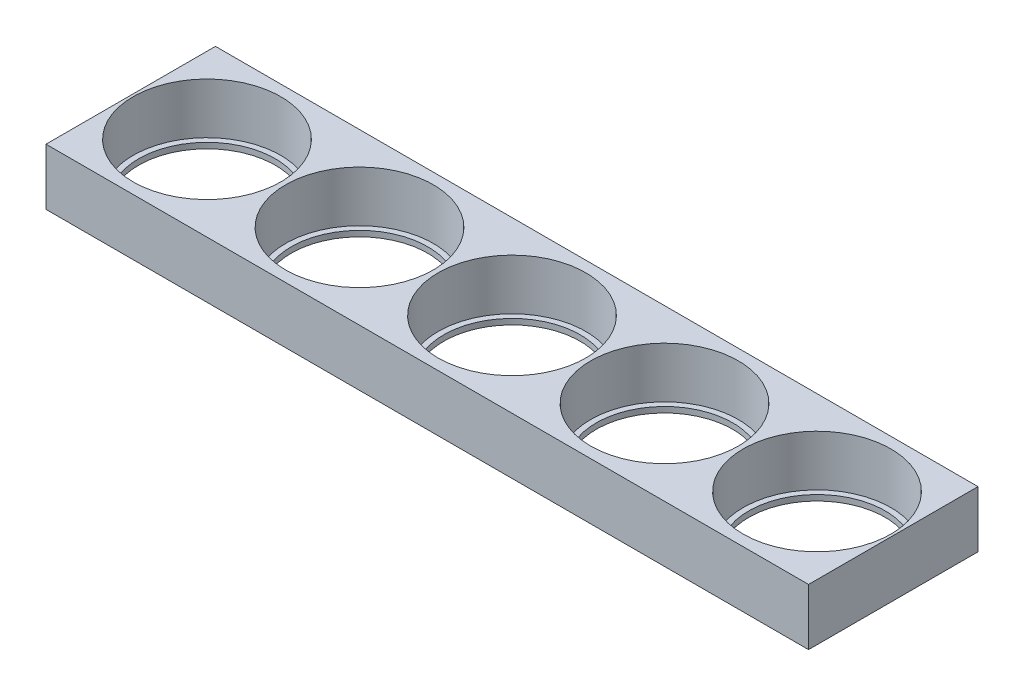
from build123d import *

# Parameters (mm, degrees)
ESQUISSE1_W                    = 27
ESQUISSE1_H                    = 30
ESQUISSE1_R                    = 13.075
BOSS_EXTRU_1_DEPTH             = 10
ESQUISSE4_R                    = 13.075
ESQUISSE4_R_2                  = 12.075
BOSS_EXTRU_2_DEPTH             = 1
R_P_TITION_LIN_AIRE1_COUNT     = 3
R_P_TITION_LIN_AIRE1_PITCH     = 27
R_P_TITION_LIN_AIRE1_COL_COUNT = 3
R_P_TITION_LIN_AIRE1_COL_PITCH = 27


with BuildPart() as part:
    # Esquisse1 → Boss.-Extru.1 (new body)
    with BuildSketch(Plane(origin=(0, 0, 0), x_dir=(1, 0, 0), z_dir=(0, 1, 0))):
        Rectangle(ESQUISSE1_W, ESQUISSE1_H)
        Circle(ESQUISSE1_R, mode=Mode.SUBTRACT)
    boss_extru_1 = extrude(amount=BOSS_EXTRU_1_DEPTH)

    # Esquisse4 → Boss.-Extru.2 (add)
    with BuildSketch(Plane(origin=(0, 0, 0), x_dir=(1, 0, 0), z_dir=(0, 1, 0))):
        Circle(ESQUISSE4_R)
        Circle(ESQUISSE4_R_2, mode=Mode.SUBTRACT)
    boss_extru_2 = extrude(amount=BOSS_EXTRU_2_DEPTH)

    # Répétition linéaire1: Boss.-Extru.1, Boss.-Extru.2 ×3
    with Locations(*[(i * R_P_TITION_LIN_AIRE1_PITCH, 0, 0) for i in range(1, R_P_TITION_LIN_AIRE1_COUNT)]):
        add(boss_extru_1)
        add(boss_extru_2)

    # Répétition linéaire1 col: Boss.-Extru.1, Boss.-Extru.2 ×3
    with Locations(*[(-i * R_P_TITION_LIN_AIRE1_COL_PITCH, 0, 0) for i in range(1, R_P_TITION_LIN_AIRE1_COL_COUNT)]):
        add(boss_extru_1)
        add(boss_extru_2)


solid = part.part
